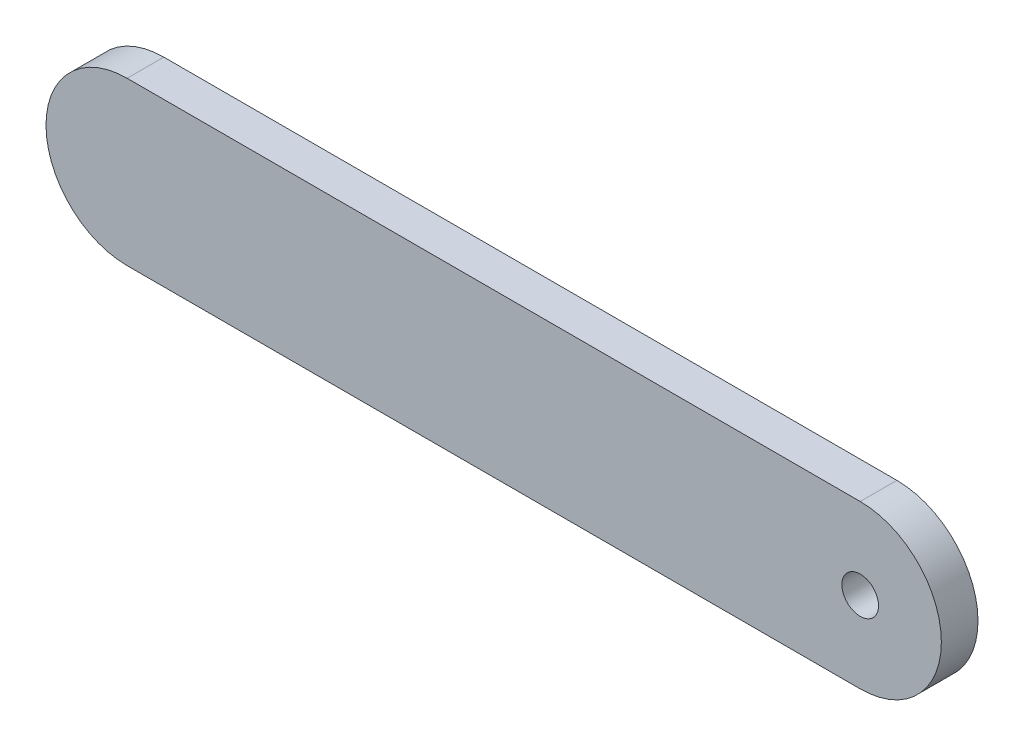
from build123d import *

# Parameters (mm, degrees)
SKETCH1_R           = 1.5
BOSS_EXTRUDE1_DEPTH = 3


with BuildPart() as part:
    # Sketch1 → Boss-Extrude1 (new body)
    with BuildSketch(Plane.XY):
        with BuildLine():
            Line((-18.39653012, 6.642056017), (41.60346988, 6.642056017))
            ThreePointArc((41.60346988, 6.642056017), (48.245525897, 0), (41.60346988, -6.642056017))
            Line((41.60346988, -6.642056017), (-18.39653012, -6.642056017))
            ThreePointArc((-18.39653012, -6.642056017), (-25.038586136, 0), (-18.39653012, 6.642056017))
        make_face()
        with Locations((41.60346988, 0)):
            Circle(SKETCH1_R, mode=Mode.SUBTRACT)
    extrude(amount=BOSS_EXTRUDE1_DEPTH)


solid = part.part
